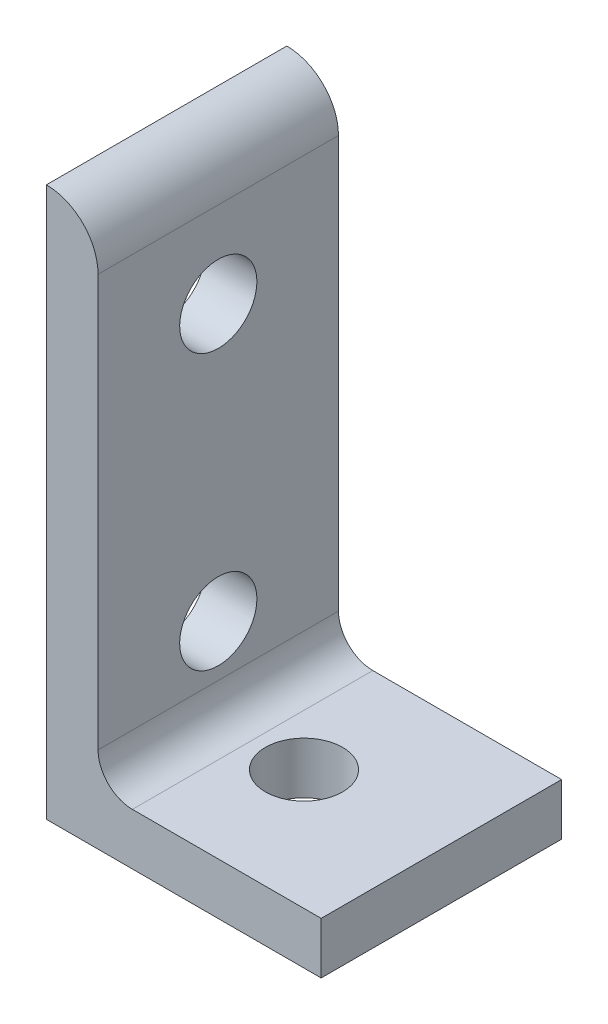
from build123d import *

# Parameters (mm, degrees)
BOSS_EXTRUDE1_DEPTH = 11.1125
SKETCH2_R           = 3.5687
CUT_EXTRUDE1_DEPTH  = 51.8
SKETCH3_R           = 3.5687
CUT_EXTRUDE2_DEPTH  = 51.8
CUT_EXTRUDE3_REACH  = 6.775
SKETCH4_W           = 25.4
SKETCH4_H           = 22.225


with BuildPart() as part:
    # Sketch1 → Boss-Extrude1 (new body, symmetric)
    with BuildSketch(Plane.XY):
        with BuildLine():
            Line((0, 0), (0, 50.8))
            ThreePointArc((0, 50.8), (3.376576302, 49.401376302), (4.7752, 46.0248))
            Line((4.7752, 46.0248), (4.7752, 7.9502))
            ThreePointArc((4.7752, 7.9502), (5.70513597, 5.70513597), (7.9502, 4.7752))
            Line((7.9502, 4.7752), (46.0248, 4.7752))
            ThreePointArc((46.0248, 4.7752), (49.401376302, 3.376576302), (50.8, 0))
            Line((50.8, 0), (0, 0))
        make_face()
    extrude(amount=BOSS_EXTRUDE1_DEPTH, both=True)

    # Sketch2 → Cut-Extrude1 (cut, through all)
    with BuildSketch(Plane(origin=(0, 0, 0), x_dir=(1, 0, 0), z_dir=(0, 1, 0))):
        with Locations((12.7, 0)):
            Circle(SKETCH2_R)
        with Locations((38.1, 0)):
            Circle(SKETCH2_R)
    extrude(amount=CUT_EXTRUDE1_DEPTH, mode=Mode.SUBTRACT)

    # Sketch3 → Cut-Extrude2 (cut, through all)
    with BuildSketch(Plane(origin=(0, 0, 0), x_dir=(0, 0, -1), z_dir=(1, 0, 0))):
        with Locations((0, 12.7)):
            Circle(SKETCH3_R)
        with Locations((0, 38.1)):
            Circle(SKETCH3_R)
    extrude(amount=CUT_EXTRUDE2_DEPTH, mode=Mode.SUBTRACT)

    # Sketch4 → Cut-Extrude3 (cut, up to next)
    with BuildSketch(Plane(origin=(0, 4.7752, 0), x_dir=(1, 0, 0), z_dir=(0, 1, 0)), mode=Mode.PRIVATE) as cut_extrude3_sk1:
        with Locations((38.1, 0)):
            Rectangle(SKETCH4_W, SKETCH4_H)
    cut_extrude3_tool1 = extrude(cut_extrude3_sk1.sketch, amount=-CUT_EXTRUDE3_REACH, mode=Mode.PRIVATE) & part.part
    add(cut_extrude3_tool1.solids().sort_by_distance((38.1, 4.7752, 0))[0], mode=Mode.SUBTRACT)


solid = part.part
